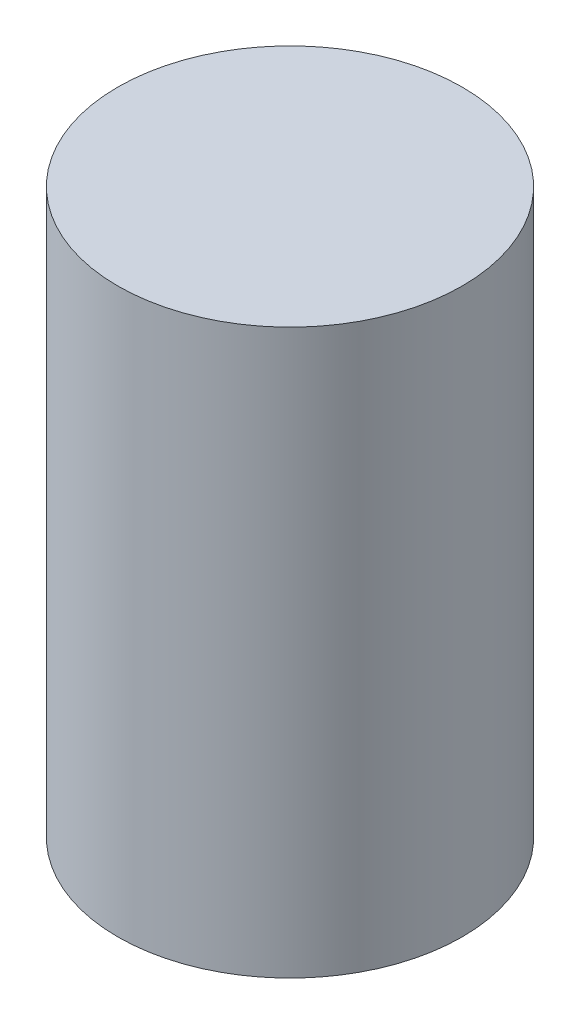
from build123d import *

# Parameters (mm, degrees)
SKETCH1_R           = 5.5
BOSS_EXTRUDE1_DEPTH = 18


with BuildPart() as part:
    # Sketch1 → Boss-Extrude1 (new body)
    with BuildSketch(Plane(origin=(0, 0, 0), x_dir=(1, 0, 0), z_dir=(0, 1, 0))):
        Circle(SKETCH1_R)
    extrude(amount=BOSS_EXTRUDE1_DEPTH)


solid = part.part
